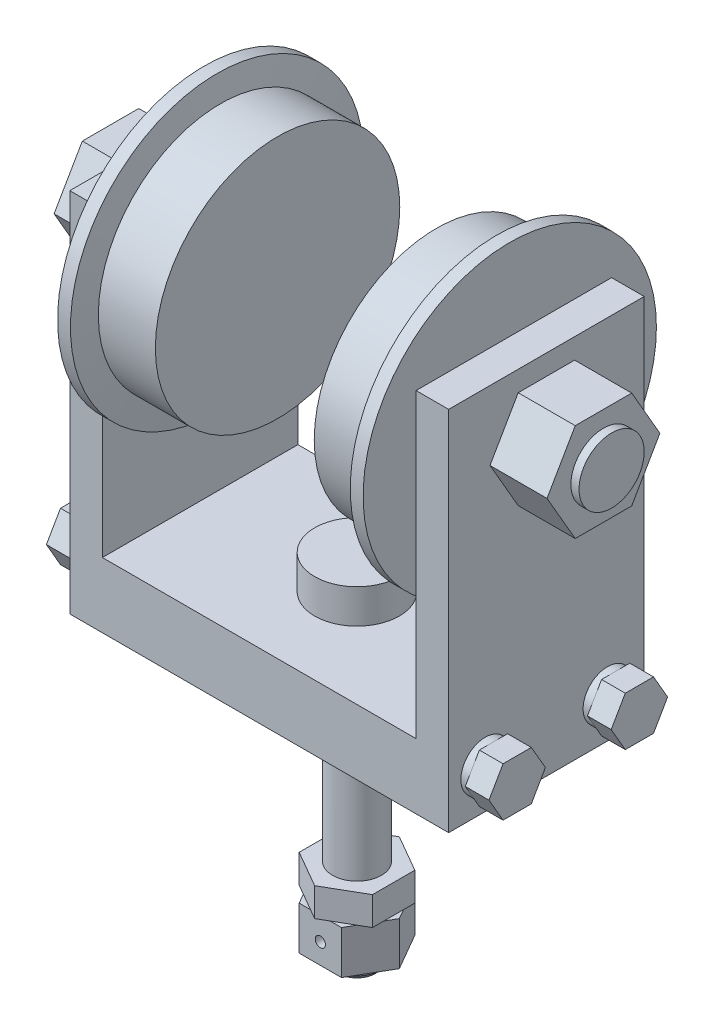
from build123d import *

# Parameters (mm, degrees)
YOKE_CROSS_SECTION_W           = 76.2
YOKE_CROSS_SECTION_H           = 25.4
YOKE_DEPTH                     = 61.11875
SIDEPLATE_PROFILE_W            = 76.2
SIDEPLATE_PROFILE_H            = 142.875
SIDEPLATE_DEPTH                = 12.7
WHEEL_PIN_NUT_DEPTH            = 22.225
WHEEL_PIN_PROJECTION_PROFILE_R = 12.7
WHEEL_PIN_PROJECTION_DEPTH     = 3.175
LOCKNUTS_PROFILE_R             = 9.525
LOCKNUTS_DEPTH                 = 3.175
SCREWS_DEPTH                   = 9.2456
PROFILE_R                      = 16.4973
KING_BOLT_HEAD_DEPTH           = 13.3096
DIA_R                          = 9.525
KING_BOLT_DEPTH                = 65.589601
KING_BOLT_JAM_NUT_DEPTH        = 11.1125
KING_BOLT_NUT_DEPTH            = 16.891
SKETCH5_R                      = 9.525
EXTENDED_KING_BOLT_DEPTH       = 6.35
CHAMFER1_SIZE                  = 2.38125
COTTER_PIN_HOLE_REACH          = 73.437
SKETCH8_R                      = 1.984375


with BuildPart() as part:
    # YOKE CROSS SECTION → YOKE (new body)
    with BuildSketch(Plane(origin=(0, 0, 0), x_dir=(0, 0, -1), z_dir=(1, 0, 0))):
        with Locations((0, 12.7)):
            Rectangle(YOKE_CROSS_SECTION_W, YOKE_CROSS_SECTION_H)
    extrude(amount=YOKE_DEPTH)

    # SIDEPLATE PROFILE → SIDEPLATE (add)
    with BuildSketch(Plane(origin=(61.11875, 0, 0), x_dir=(0, 0, -1), z_dir=(1, 0, 0))):
        with Locations((0, 71.4375)):
            Rectangle(SIDEPLATE_PROFILE_W, SIDEPLATE_PROFILE_H)
    extrude(amount=SIDEPLATE_DEPTH)

    # WHEEL PIN NUT PROFILE → WHEEL PIN NUT (add)
    with BuildSketch(Plane(origin=(73.81875, 0, 0), x_dir=(0, 0, -1), z_dir=(1, 0, 0))):
        Polygon((21.997045256, 115.8875), (10.998522628, 134.9375), (-10.998522628, 134.9375), (-21.997045256, 115.8875), (-10.998522628, 96.8375), (10.998522628, 96.8375), align=None)
    extrude(amount=WHEEL_PIN_NUT_DEPTH)

    # WHEEL PIN PROJECTION PROFILE → WHEEL PIN PROJECTION (add)
    with BuildSketch(Plane(origin=(96.04375, 0, 0), x_dir=(0, 0, -1), z_dir=(1, 0, 0))):
        with Locations((0, 115.8875)):
            Circle(WHEEL_PIN_PROJECTION_PROFILE_R)
    extrude(amount=WHEEL_PIN_PROJECTION_DEPTH)

    # LOCKNUTS PROFILE → LOCKNUTS (add)
    with BuildSketch(Plane(origin=(73.81875, 0, 0), x_dir=(0, 0, -1), z_dir=(1, 0, 0))):
        with Locations((-23.8125, 15.563196315)):
            Circle(LOCKNUTS_PROFILE_R)
    locknuts = extrude(amount=LOCKNUTS_DEPTH)

    # SCREWS PROFILE → SCREWS (add)
    with BuildSketch(Plane(origin=(76.99375, 0, 0), x_dir=(0, 0, -1), z_dir=(1, 0, 0))):
        Polygon((-12.813977372, 15.563196315), (-18.313238686, 25.088196315), (-29.311761314, 25.088196315), (-34.811022628, 15.563196315), (-29.311761314, 6.038196315), (-18.313238686, 6.038196315), align=None)
    screws = extrude(amount=SCREWS_DEPTH)

    # PROFILE → KING BOLT HEAD (add)
    with BuildSketch(Plane(origin=(0, 25.4, 0), x_dir=(-1, 0, 0), z_dir=(0, 1, 0))):
        with Locations(Location((0, 0, 0), (0, 0, 90))):  # turned: the seam where the file's is
            Circle(PROFILE_R)
    extrude(amount=KING_BOLT_HEAD_DEPTH)

    # Mirror1: LOCKNUTS, SCREWS across plane
    add(locknuts.mirror(Plane.XY))
    add(screws.mirror(Plane.XY))

    # Mirror5: part across plane


with BuildPart() as part_1:
    add(part.part)
    add(part.part.mirror(Plane(origin=(0, 0, 0), x_dir=(0, 0, 1), z_dir=(1, 0, 0))))

    # DIA. → KING BOLT (add)
    with BuildSketch(Plane.XZ):
        with Locations(Location((0, 0, 0), (0, 0, 90))):  # turned: the seam where the file's is
            Circle(DIA_R)
    extrude(amount=KING_BOLT_DEPTH)

    # KING BOLT JAN NUT PROFILE → KING BOLT JAM NUT (add)
    with BuildSketch(Plane.XZ.offset(65.589600888)):
        Polygon((0, -16.497783942), (14.2875, -8.248891971), (14.2875, 8.248891971), (0, 16.497783942), (-14.2875, 8.248891971), (-14.2875, -8.248891971), align=None)
    extrude(amount=KING_BOLT_JAM_NUT_DEPTH)

    # KING BOLT NUT PROFILE → KING BOLT NUT (add)
    with BuildSketch(Plane.XZ.offset(76.702100888)):
        Polygon((16.497783942, 0), (8.248891971, 14.2875), (-8.248891971, 14.2875), (-16.497783942, 0), (-8.248891971, -14.2875), (8.248891971, -14.2875), align=None)
    extrude(amount=KING_BOLT_NUT_DEPTH)

    # Sketch5 → EXTENDED KING BOLT (add)
    with BuildSketch(Plane.XZ.offset(93.593100888)):
        with Locations(Location((0, 0, 0), (0, 0, 90))):  # turned: the seam where the file's is
            Circle(SKETCH5_R)
    extrude(amount=EXTENDED_KING_BOLT_DEPTH)

    # Chamfer1
    chamfer1_edges = [part_1.edges().sort_by_distance(p)[0] for p in [
        (0, -99.943100888, -9.525),
    ]]
    chamfer(chamfer1_edges, length=CHAMFER1_SIZE)

    # Sketch7 → WHEEL (revolve)
    with BuildSketch(Plane.XY, mode=Mode.PRIVATE) as wheel_sk:
        Polygon((59.53125, 173.0375), (54.519901451, 173.0375), (53.18125, 163.5125), (30.95625, 163.5125), (30.95625, 115.8875), (61.11875, 115.8875), (61.11875, 131.7625), (59.53125, 131.7625), align=None)
    wheel = revolve(wheel_sk.sketch.rotate(Axis((99.21875, 115.8875, 0), (-1, 0, 0)), 90), axis=Axis((99.21875, 115.8875, 0), (-1, 0, 0)))  # turned: the seam where the file's is

    # Mirror6: WHEEL across plane
    add(wheel.mirror(Plane(origin=(0, 0, 0), x_dir=(0, 0, 1), z_dir=(1, 0, 0))))

    # Sketch8 → COTTER PIN HOLE (cut, up to next)
    with BuildSketch(Plane.XY.offset(14.2875), mode=Mode.PRIVATE) as cotter_pin_hole_sk1:
        with Locations((0, -85.655600888)):
            Circle(SKETCH8_R)
    cotter_pin_hole_tool1 = extrude(cotter_pin_hole_sk1.sketch, amount=-COTTER_PIN_HOLE_REACH, mode=Mode.PRIVATE) & part_1.part
    add(cotter_pin_hole_tool1.solids().sort_by_distance((0, -85.655601, 14.2875))[0], mode=Mode.SUBTRACT)


solid = part_1.part
